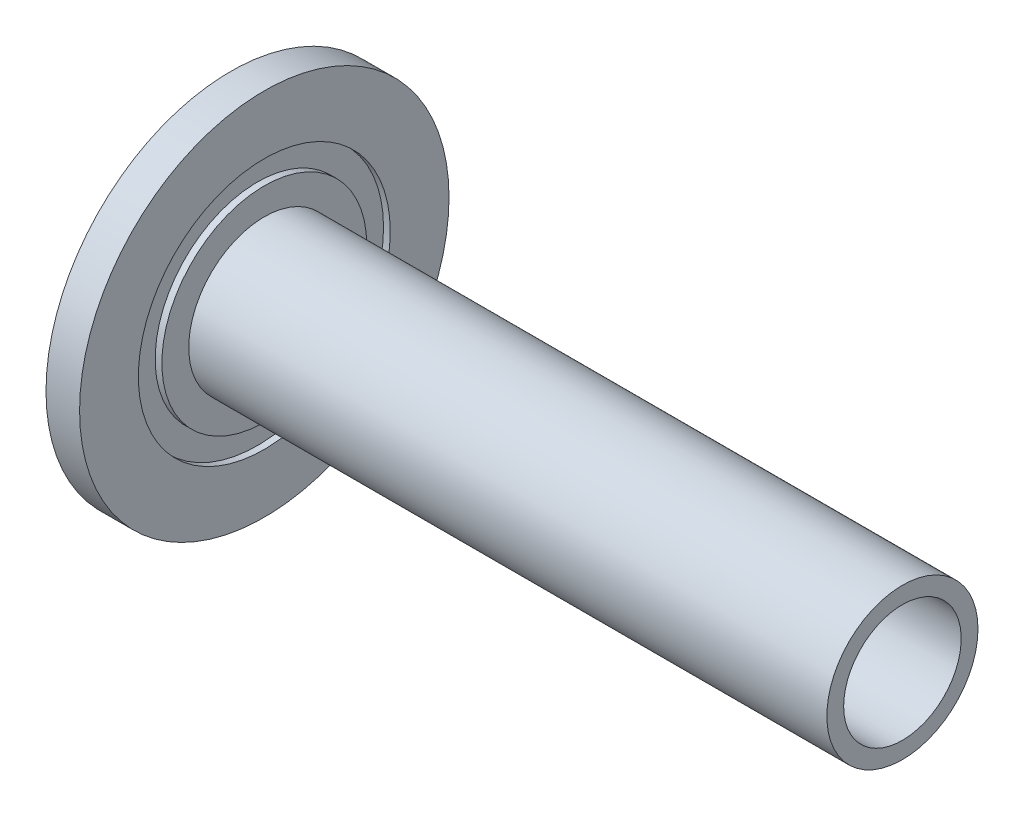
from build123d import *

# Parameters (mm, degrees)
SKETCH2_R               = 55
BOSS_EXTRUDE1_DEPTH     = 10
SKETCH3_R               = 22.5
BOSS_EXTRUDE2_DEPTH     = 190
SKETCH4_R               = 17.5
CUT_EXTRUDE1_DEPTH      = 1
CUT_EXTRUDE1_DEPTH_BACK = 201
SKETCH14_R              = 37.5
SKETCH14_R_2            = 30.5
CUT_EXTRUDE5_DEPTH      = 1
SKETCH15_R              = 37.5
SKETCH15_R_2            = 30.5
CUT_EXTRUDE6_DEPTH      = 2
SKETCH16_R              = 2.5
CUT_EXTRUDE7_DEPTH      = 4
SKETCH17_R              = 5
CUT_EXTRUDE8_DEPTH      = 2


with BuildPart() as part:
    # Sketch2 → Boss-Extrude1 (new body)
    with BuildSketch(Plane(origin=(0, 0, 0), x_dir=(0, 0, -1), z_dir=(1, 0, 0))):
        Circle(SKETCH2_R)
    extrude(amount=BOSS_EXTRUDE1_DEPTH)

    # Sketch3 → Boss-Extrude2 (add)
    with BuildSketch(Plane(origin=(10, 0, 0), x_dir=(0, 0, -1), z_dir=(1, 0, 0))):
        Circle(SKETCH3_R)
    extrude(amount=BOSS_EXTRUDE2_DEPTH)

    # Sketch4 → Cut-Extrude1 (cut, two sides)
    with BuildSketch(Plane.ZY) as cut_extrude1_sk:
        Circle(SKETCH4_R)
    extrude(amount=CUT_EXTRUDE1_DEPTH, mode=Mode.SUBTRACT)
    extrude(cut_extrude1_sk.sketch, amount=-CUT_EXTRUDE1_DEPTH_BACK, mode=Mode.SUBTRACT)

    # Sketch14 → Cut-Extrude5 (cut)
    with BuildSketch(Plane.ZY):
        Circle(SKETCH14_R)
        Circle(SKETCH14_R_2, mode=Mode.SUBTRACT)
    extrude(amount=-CUT_EXTRUDE5_DEPTH, mode=Mode.SUBTRACT)

    # Sketch15 → Cut-Extrude6 (cut)
    with BuildSketch(Plane(origin=(10, 0, 0), x_dir=(0, 0, -1), z_dir=(1, 0, 0))):
        Circle(SKETCH15_R)
        Circle(SKETCH15_R_2, mode=Mode.SUBTRACT)
    extrude(amount=-CUT_EXTRUDE6_DEPTH, mode=Mode.SUBTRACT)

    # Sketch16 → Cut-Extrude7 (cut)
    with BuildSketch(Plane.ZY):
        with Locations((0, 34)):
            Circle(SKETCH16_R)
        with Locations((0, -34)):
            Circle(SKETCH16_R)
    extrude(amount=-CUT_EXTRUDE7_DEPTH, mode=Mode.SUBTRACT)

    # Sketch17 → Cut-Extrude8 (cut)
    with BuildSketch(Plane.ZY):
        with Locations((0, -34)):
            Circle(SKETCH17_R)
        with Locations((0, 34)):
            Circle(SKETCH17_R)
    extrude(amount=-CUT_EXTRUDE8_DEPTH, mode=Mode.SUBTRACT)


solid = part.part
